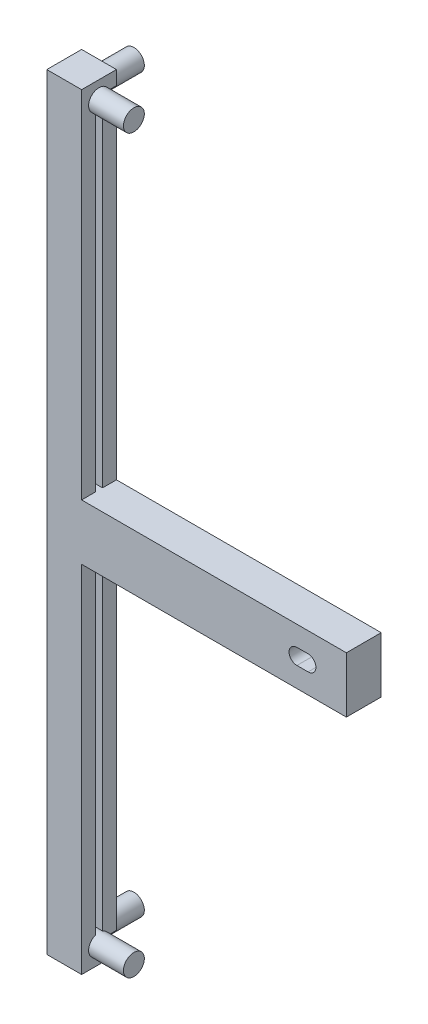
from build123d import *

# Parameters (mm, degrees)
CROQUIS2_W                   = 220
CROQUIS2_H                   = 220
CROQUIS2_W_2                 = 200
CROQUIS2_H_2                 = 200
SALIENTE_EXTRUIR1_DEPTH      = 10
CROQUIS3_W                   = 212
CROQUIS3_H                   = 212
CROQUIS3_W_2                 = 210
CROQUIS3_H_2                 = 210
CROQUIS3_W_3                 = 208
CROQUIS3_H_3                 = 208
CORTAR_EXTRUIR1_DEPTH        = 3.5
CROQUIS4_W                   = 10
CROQUIS4_H                   = 10
SALIENTE_EXTRUIR2_DEPTH      = 200
SALIENTE_EXTRUIR2_DEPTH_BACK = 10
CROQUIS6_W                   = 3.5
CROQUIS6_H                   = 2
CROQUIS6_W_2                 = 2
CROQUIS6_H_2                 = 3.5
CROQUIS6_W_3                 = 1.99805467
CORTAR_EXTRUIR2_DEPTH        = 203.5
CROQUIS7_W                   = 220
CROQUIS7_H                   = 220
CROQUIS7_W_2                 = 200
CROQUIS7_H_2                 = 200
SALIENTE_EXTRUIR3_DEPTH      = 10
CORTAR_EXTRUIR3_START        = -3.5
CROQUIS8_W                   = 207
CROQUIS8_H                   = 2
CORTAR_EXTRUIR3_DEPTH        = 207
MATRIZC1_COUNT               = 4
CROQUIS9_W                   = 86
CROQUIS9_H                   = 16
BRAZOS_DEPTH                 = 10
MATRIZC2_COUNT               = 4
CROQUIS10_W                  = 253.040518898
CROQUIS10_H                  = 245.473998616
BORRADOA_DEPTH               = 221
BORRADOB_DEPTH               = 11
SALIENTE_EXTRUIR4_START      = -6
CROQUIS12_R                  = 3
SALIENTE_EXTRUIR4_DEPTH      = 16
CROQUIS13_R                  = 3
SALIENTE_EXTRUIR5_DEPTH      = 10
SALIENTE_EXTRUIR5_DEPTH_BACK = 10


with BuildPart() as part:
    # Croquis2 → Saliente-Extruir1 (new body)
    with BuildSketch(Plane.XY):
        with Locations((110, -110)):
            Rectangle(CROQUIS2_W, CROQUIS2_H)
        with Locations((110, -110)):
            Rectangle(CROQUIS2_W_2, CROQUIS2_H_2, mode=Mode.SUBTRACT)
    extrude(amount=SALIENTE_EXTRUIR1_DEPTH)

    # Croquis3 → Cortar-Extruir1 (cut)
    with BuildSketch(Plane.XY.offset(10)):
        with Locations((110, -110)):
            Rectangle(CROQUIS3_W, CROQUIS3_H)
        with Locations((110, -110)):
            Rectangle(CROQUIS3_W_2, CROQUIS3_H_2, mode=Mode.SUBTRACT)
        with Locations((110, -110)):
            Rectangle(CROQUIS3_W_2, CROQUIS3_H_2)
        with Locations((110, -110)):
            Rectangle(CROQUIS3_W_3, CROQUIS3_H_3, mode=Mode.SUBTRACT)
    extrude(amount=-CORTAR_EXTRUIR1_DEPTH, mode=Mode.SUBTRACT)

    # Croquis4 → Saliente-Extruir2 (add, two sides)
    with BuildSketch(Plane.XY.offset(10)) as saliente_extruir2_sk:
        with Locations((5, -5)):
            Rectangle(CROQUIS4_W, CROQUIS4_H)
        with Locations((215, -5)):
            Rectangle(CROQUIS4_W, CROQUIS4_H)
        with Locations((215, -215)):
            Rectangle(CROQUIS4_W, CROQUIS4_H)
        with Locations((5, -215)):
            Rectangle(CROQUIS4_W, CROQUIS4_H)
    extrude(amount=SALIENTE_EXTRUIR2_DEPTH)
    extrude(saliente_extruir2_sk.sketch, amount=-SALIENTE_EXTRUIR2_DEPTH_BACK)

    # Croquis6 → Cortar-Extruir2 (cut)
    with BuildSketch(Plane.XY.offset(210)):
        with Locations((8.25, -5)):
            Rectangle(CROQUIS6_W, CROQUIS6_H)
        with Locations((5, -8.25)):
            Rectangle(CROQUIS6_W_2, CROQUIS6_H_2)
        with Locations((211.75, -5)):
            Rectangle(CROQUIS6_W, CROQUIS6_H)
        with Locations((215, -8.25)):
            Rectangle(CROQUIS6_W_2, CROQUIS6_H_2)
        with Locations((211.75, -215)):
            Rectangle(CROQUIS6_W, CROQUIS6_H)
        with Locations((215.000972665, -211.75)):
            Rectangle(CROQUIS6_W_3, CROQUIS6_H_2)
        with Locations((5, -211.75)):
            Rectangle(CROQUIS6_W_2, CROQUIS6_H_2)
        with Locations((8.25, -215)):
            Rectangle(CROQUIS6_W, CROQUIS6_H)
    extrude(amount=-CORTAR_EXTRUIR2_DEPTH, mode=Mode.SUBTRACT)

    # Croquis7 → Saliente-Extruir3 (add)
    with BuildSketch(Plane.XY.offset(210)):
        with Locations((110, -110)):
            Rectangle(CROQUIS7_W, CROQUIS7_H)
        with Locations((110, -110)):
            Rectangle(CROQUIS7_W_2, CROQUIS7_H_2, mode=Mode.SUBTRACT)
    extrude(amount=SALIENTE_EXTRUIR3_DEPTH)

    # Croquis8 → Cortar-Extruir3 (cut)
    with BuildSketch(Plane(origin=(0, -210, 0), x_dir=(1, 0, 0), z_dir=(0, 1, 0)).offset(CORTAR_EXTRUIR3_START)):
        with Locations((110, -215)):
            Rectangle(CROQUIS8_W, CROQUIS8_H)
    cortar_extruir3 = extrude(amount=CORTAR_EXTRUIR3_DEPTH, mode=Mode.SUBTRACT)

    # MatrizC1: Cortar-Extruir3 ×4 about axis
    matrizc1_axis = Axis((0, -110, 110), (1, 0, 0))
    for i in range(1, MATRIZC1_COUNT):
        add(cortar_extruir3.rotate(matrizc1_axis, i * 360 / MATRIZC1_COUNT), mode=Mode.SUBTRACT)

    # Croquis9 → Brazos (add)
    with BuildSketch(Plane.XY.offset(220)):
        with Locations((43, -110)):
            Rectangle(CROQUIS9_W, CROQUIS9_H)
        with BuildLine():
            ThreePointArc((71.801526277, -112.25), (69.551526277, -110), (71.801526277, -107.75))
            Line((71.801526277, -107.75), (75, -107.75))
            ThreePointArc((75, -107.75), (77.25, -110), (75, -112.25))
            Line((75, -112.25), (71.801526277, -112.25))
        make_face(mode=Mode.SUBTRACT)
        with Locations((177, -110)):
            Rectangle(CROQUIS9_W, CROQUIS9_H)
        with BuildLine():
            Line((145, -107.75), (148.198473723, -107.75))
            ThreePointArc((148.198473723, -107.75), (150.448473723, -110), (148.198473723, -112.25))
            Line((148.198473723, -112.25), (145, -112.25))
            ThreePointArc((145, -112.25), (142.75, -110), (145, -107.75))
        make_face(mode=Mode.SUBTRACT)
    extrude(amount=-BRAZOS_DEPTH)

    # MatrizC2: Cortar-Extruir3 ×4 about axis
    matrizc2_axis = Axis((110, 0, 110), (0, 1, 0))
    for i in range(1, MATRIZC2_COUNT):
        add(cortar_extruir3.rotate(matrizc2_axis, i * 360 / MATRIZC2_COUNT), mode=Mode.SUBTRACT)

    # Croquis10 → BorradoA (cut, through all)
    with BuildSketch(Plane.ZY):
        with Locations((83.479740551, -103.879873202)):
            Rectangle(CROQUIS10_W, CROQUIS10_H)
    extrude(amount=-BORRADOA_DEPTH, mode=Mode.SUBTRACT)

    # Croquis11 → BorradoB (cut, through all)
    with BuildSketch(Plane(origin=(0, 0, 210), x_dir=(-1, 0, 0), z_dir=(0, 0, -1))):
        Polygon((-10, -56), (-98.55448729, -56), (-98.55448729, -158.528956518), (-10, -158.528956518), (-10, -243.106080237), (-103.852362771, -243.106080237), (-103.852362771, -224.29470596), (-244.898091904, -224.29470596), (-244.898091904, -56), (-244.898091904, 3.811722284), (-10, 3.811722284), align=None)
    extrude(amount=-BORRADOB_DEPTH, mode=Mode.SUBTRACT)

    # Croquis12 → Saliente-Extruir4 (add)
    with BuildSketch(Plane(origin=(10, 0, 0), x_dir=(0, 0, -1), z_dir=(1, 0, 0)).offset(SALIENTE_EXTRUIR4_START)):
        with Locations((-215, -5)):
            Circle(CROQUIS12_R)
        with Locations((-215, -215)):
            Circle(CROQUIS12_R)
    extrude(amount=SALIENTE_EXTRUIR4_DEPTH)

    # Croquis13 → Saliente-Extruir5 (add, two sides)
    with BuildSketch(Plane(origin=(0, 0, 210), x_dir=(-1, 0, 0), z_dir=(0, 0, -1))) as saliente_extruir5_sk:
        with Locations((-5, -5)):
            Circle(CROQUIS13_R)
        with Locations((-5, -215)):
            Circle(CROQUIS13_R)
    extrude(amount=SALIENTE_EXTRUIR5_DEPTH)
    extrude(saliente_extruir5_sk.sketch, amount=-SALIENTE_EXTRUIR5_DEPTH_BACK)


solid = part.part
